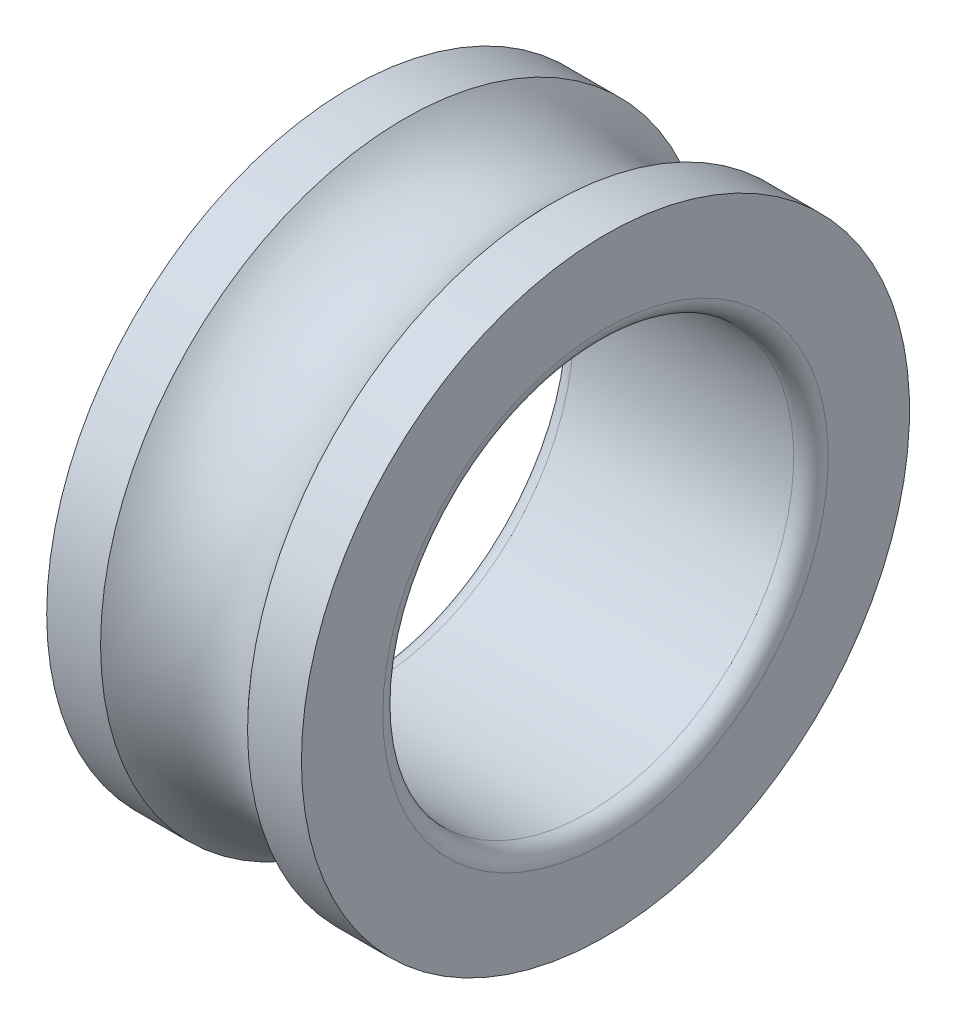
from build123d import *


with BuildPart() as part:
    # Sketch1 → Revolve1 (revolve)
    with BuildSketch(Plane.XY):
        with BuildLine():
            Line((-15.5, 37), (-8.94427191, 37))
            ThreePointArc((-8.94427191, 37), (0, 33), (8.94427191, 37))
            Line((8.94427191, 37), (15.5, 37))
            Line((15.5, 37), (15.5, 27.1))
            ThreePointArc((15.5, 27.1), (14.88492424, 25.61507576), (13.4, 25))
            Line((13.4, 25), (-13.4, 25))
            ThreePointArc((-13.4, 25), (-14.88492424, 25.61507576), (-15.5, 27.1))
            Line((-15.5, 27.1), (-15.5, 37))
        make_face()
    revolve(axis=Axis((-29.583333333, 0, 0), (1, 0, 0)))


solid = part.part
